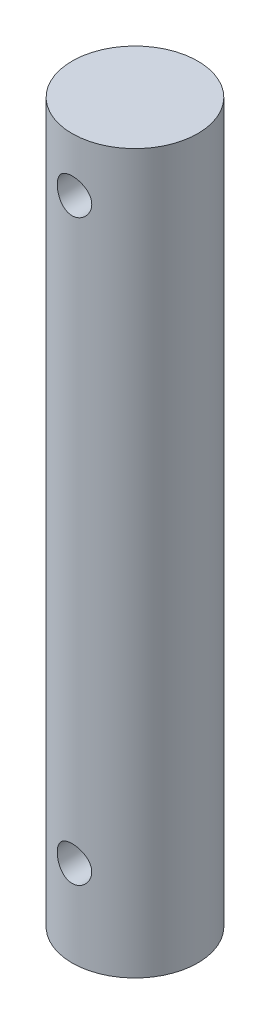
from build123d import *

# Parameters (mm, degrees)
SKETCH1_R                  = 5.55625
BOSS_EXTRUDE1_DEPTH        = 63.5
F_31_0_12_DIAMETER_HOLE1_D = 3.048


with BuildPart() as part:
    # Sketch1 → Boss-Extrude1 (new body)
    with BuildSketch(Plane(origin=(0, 0, 0), x_dir=(1, 0, 0), z_dir=(0, 1, 0))):
        Circle(SKETCH1_R)
    extrude(amount=BOSS_EXTRUDE1_DEPTH)

    # #31 (0.12) Diameter Hole1 (through all)
    with Locations(Plane.XY.offset(5.55625)):
        with Locations((0, 58.7375), (0, 7.62)):
            Hole(F_31_0_12_DIAMETER_HOLE1_D / 2)


solid = part.part
